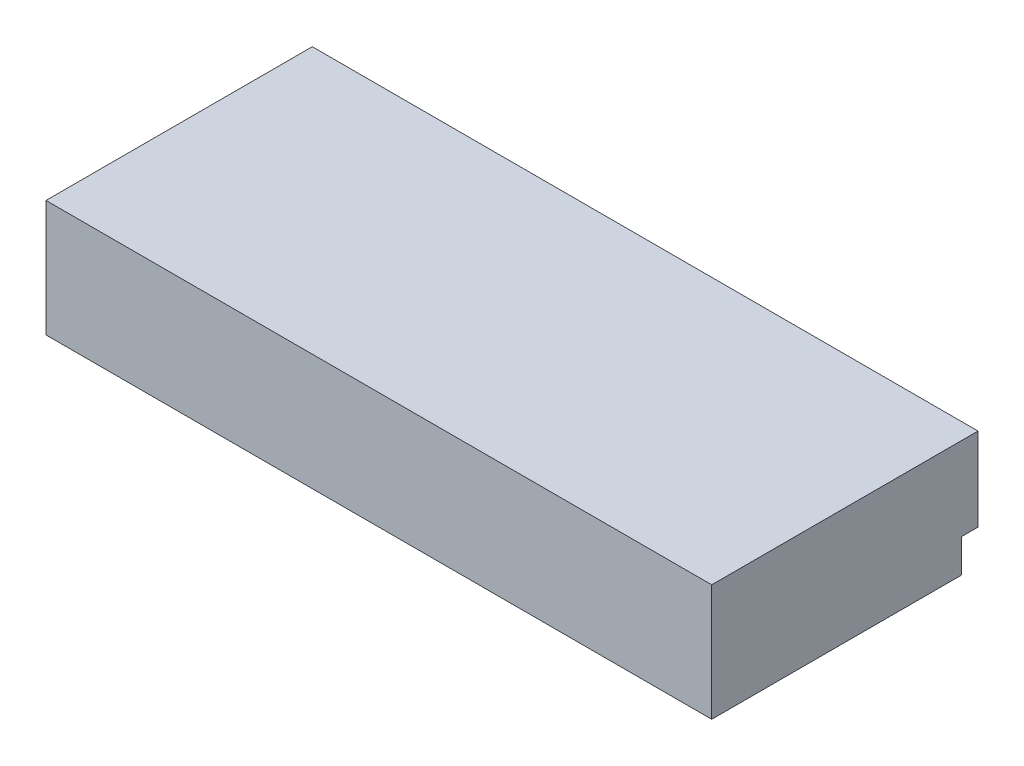
from build123d import *

# Parameters (mm, degrees)
SKETCH1_W           = 200
SKETCH1_H           = 80
BOSS_EXTRUDE1_DEPTH = 35
SKETCH2_W           = 5
SKETCH2_H           = 10
CUT_EXTRUDE1_DEPTH  = 201


with BuildPart() as part:
    # Sketch1 → Boss-Extrude1 (new body)
    with BuildSketch(Plane(origin=(0, 0, 0), x_dir=(1, 0, 0), z_dir=(0, 1, 0))):
        Rectangle(SKETCH1_W, SKETCH1_H)
    extrude(amount=BOSS_EXTRUDE1_DEPTH)

    # Sketch2 → Cut-Extrude1 (cut, through all)
    with BuildSketch(Plane(origin=(100, 0, 0), x_dir=(0, 0, -1), z_dir=(1, 0, 0))):
        with Locations((37.5, 5)):
            Rectangle(SKETCH2_W, SKETCH2_H)
    extrude(amount=-CUT_EXTRUDE1_DEPTH, mode=Mode.SUBTRACT)


solid = part.part
